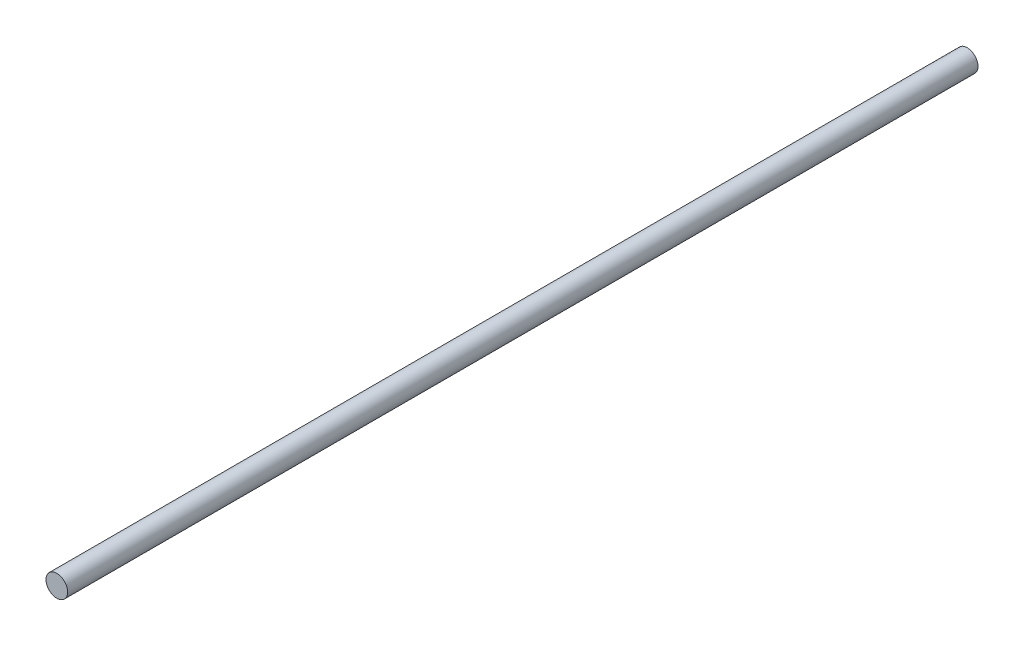
from build123d import *

# Parameters (mm, degrees)
SKETCH1_R           = 1.9
BOSS_EXTRUDE1_DEPTH = 160


with BuildPart() as part:
    # Sketch1 → Boss-Extrude1 (new body)
    with BuildSketch(Plane.XY):
        Circle(SKETCH1_R)
    extrude(amount=BOSS_EXTRUDE1_DEPTH)


solid = part.part
